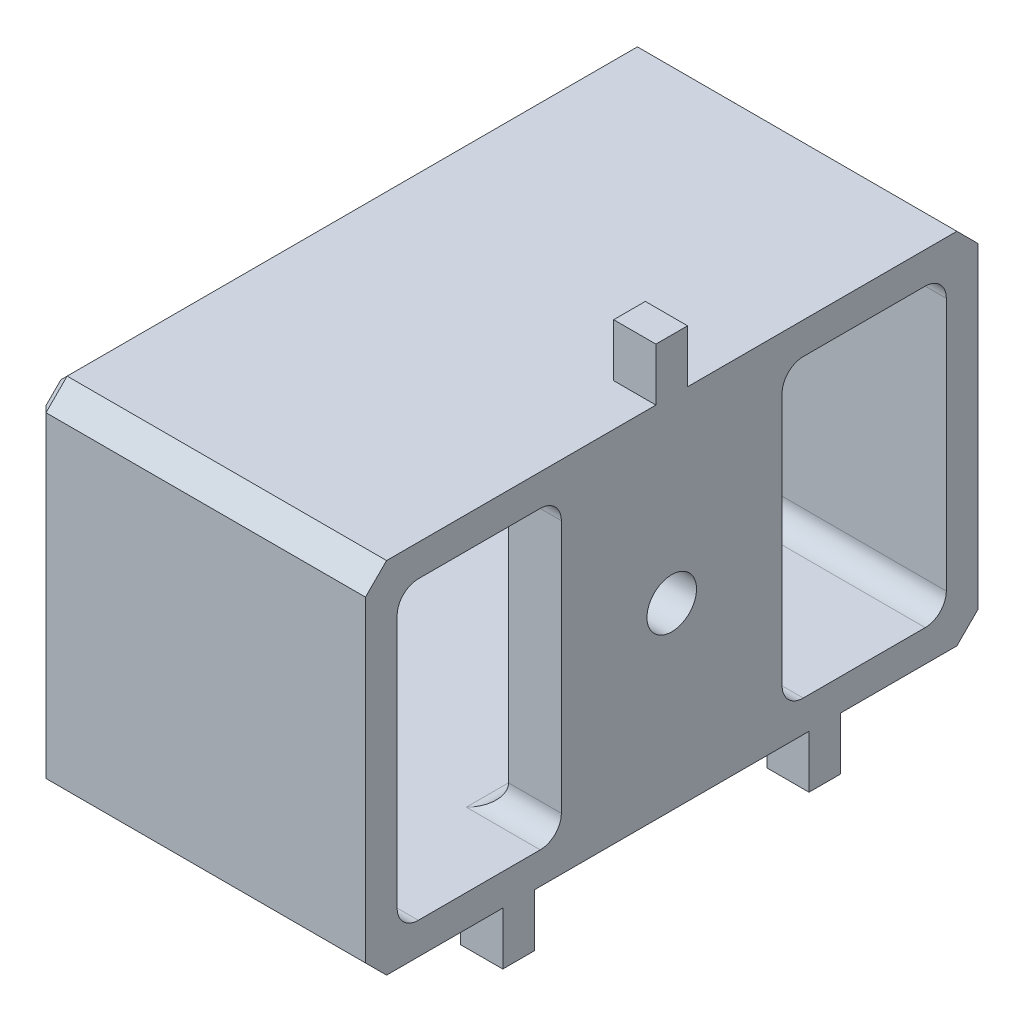
from build123d import *

# Parameters (mm, degrees)
SKETCH2_W             = 14.732
SKETCH2_H             = 8.636
SKETCH2_W_2           = 13.208
SKETCH2_H_2           = 7.112
EXTRUDE_THIN1_DEPTH   = 7.9375
SKETCH3_W             = 14.732
SKETCH3_H             = 8.636
BOSS_EXTRUDE1_DEPTH   = 1.27
CUT_EXTRUDE1_REACH    = 9.938
SKETCH4_W             = 3.949
SKETCH4_H             = 7.112
SKETCH7_R             = 1.016
BOSS_EXTRUDE2_DEPTH   = 1.27
F_0_80_TAPPED_HOLE1_D = 1.19126
SKETCH9_W             = 0.762
SKETCH9_H             = 1.27
EXTRUDE_THIN2_DEPTH   = 1.27
FILLET1_R             = 0.508
CHAMFER1_SIZE         = 0.508
CHAMFER2_SIZE         = 0.254


with BuildPart() as part:
    # Sketch2 → Extrude-Thin1 (new body)
    with BuildSketch(Plane(origin=(-2.794, 0, 0), x_dir=(0, 0, -1), z_dir=(1, 0, 0))):
        with Locations((-7.366, -62.992)):
            Rectangle(SKETCH2_W, SKETCH2_H)
        with Locations((-7.366, -62.992)):
            Rectangle(SKETCH2_W_2, SKETCH2_H_2, mode=Mode.SUBTRACT)
    extrude(amount=EXTRUDE_THIN1_DEPTH)

    # Sketch3 → Boss-Extrude1 (add)
    with BuildSketch(Plane(origin=(5.1435, 0, 0), x_dir=(0, 0, -1), z_dir=(1, 0, 0))):
        with Locations((-7.366, -62.992)):
            Rectangle(SKETCH3_W, SKETCH3_H)
    extrude(amount=-BOSS_EXTRUDE1_DEPTH)

    # Sketch4 → Cut-Extrude1 (cut, up to next)
    with BuildSketch(Plane(origin=(5.1435, 0, 0), x_dir=(0, 0, -1), z_dir=(1, 0, 0)), mode=Mode.PRIVATE) as cut_extrude1_sk1:
        with Locations((-2.7365, -62.992)):
            Rectangle(SKETCH4_W, SKETCH4_H)
    cut_extrude1_tool1 = extrude(cut_extrude1_sk1.sketch, amount=-CUT_EXTRUDE1_REACH, mode=Mode.PRIVATE) & part.part
    add(cut_extrude1_tool1.solids().sort_by_distance((5.1435, -62.992, 2.7365))[0], mode=Mode.SUBTRACT)
    # Sketch4 → Cut-Extrude1 (cut, up to next)
    with BuildSketch(Plane(origin=(5.1435, 0, 0), x_dir=(0, 0, -1), z_dir=(1, 0, 0)), mode=Mode.PRIVATE) as cut_extrude1_sk2:
        with Locations((-11.9955, -62.992)):
            Rectangle(SKETCH4_W, SKETCH4_H)
    cut_extrude1_tool2 = extrude(cut_extrude1_sk2.sketch, amount=-CUT_EXTRUDE1_REACH, mode=Mode.PRIVATE) & part.part
    add(cut_extrude1_tool2.solids().sort_by_distance((5.1435, -62.992, 11.9955))[0], mode=Mode.SUBTRACT)

    # Sketch7 → Boss-Extrude2 (add)
    with BuildSketch(Plane.ZY.offset(-3.8735)):
        with Locations((7.366, -62.992)):
            Circle(SKETCH7_R)
    extrude(amount=BOSS_EXTRUDE2_DEPTH)

    # #0-80 Tapped Hole1 (through all)
    with Locations(Plane(origin=(5.1435, 0, 0), x_dir=(0, 0, -1), z_dir=(1, 0, 0))):
        with Locations((-7.366, -62.992)):
            Hole(F_0_80_TAPPED_HOLE1_D / 2)

    # Sketch9 → Extrude-Thin2 (add)
    with BuildSketch(Plane(origin=(5.1435, 0, 0), x_dir=(0, 0, -1), z_dir=(1, 0, 0))):
        with Locations((-7.366, -58.039)):
            Rectangle(SKETCH9_W, SKETCH9_H)
        with Locations((-11.049, -67.945)):
            Rectangle(SKETCH9_W, SKETCH9_H)
        with Locations((-3.683, -67.945)):
            Rectangle(SKETCH9_W, SKETCH9_H)
    extrude(amount=-EXTRUDE_THIN2_DEPTH)

    # Fillet1
    fillet1_edges = [part.edges().sort_by_distance(p)[0] for p in [
        (3.8735, -66.548, 7.366),
        (1.17475, -59.436, 13.97),
        (1.17475, -59.436, 0.762),
        (1.17475, -66.548, 0.762),
        (3.8735, -59.436, 7.366),
        (1.17475, -66.548, 13.97),
        (4.5085, -59.436, 10.021),
        (4.5085, -59.436, 4.711),
        (4.5085, -66.548, 4.711),
        (4.5085, -66.548, 10.021),
        (3.8735, -62.992, 6.35),
    ]]
    fillet(fillet1_edges, radius=FILLET1_R)

    # Chamfer1
    chamfer1_edges = [part.edges().sort_by_distance(p)[0] for p in [
        (1.17475, -67.31, 14.732),
        (1.17475, -67.31, 0),
        (1.17475, -58.674, 0),
        (1.17475, -58.674, 14.732),
    ]]
    chamfer(chamfer1_edges, length=CHAMFER1_SIZE)

    # Chamfer2
    chamfer2_edges = [part.edges().sort_by_distance(p)[0] for p in [
        (-2.794, -67.056, 14.478),
        (-2.794, -67.31, 7.366),
        (-2.794, -67.056, 0.254),
        (-2.794, -62.992, 0),
        (-2.794, -58.928, 0.254),
        (-2.794, -62.992, 14.732),
        (-2.794, -58.928, 14.478),
        (-2.794, -58.674, 7.366),
        (3.8735, -58.039, 6.985),
        (3.8735, -57.404, 7.366),
        (3.8735, -58.039, 7.747),
        (3.8735, -67.945, 10.668),
        (3.8735, -68.58, 11.049),
        (3.8735, -67.945, 11.43),
        (3.8735, -67.945, 3.302),
        (3.8735, -68.58, 3.683),
        (3.8735, -67.945, 4.064),
    ]]
    chamfer(chamfer2_edges, length=CHAMFER2_SIZE)


solid = part.part
